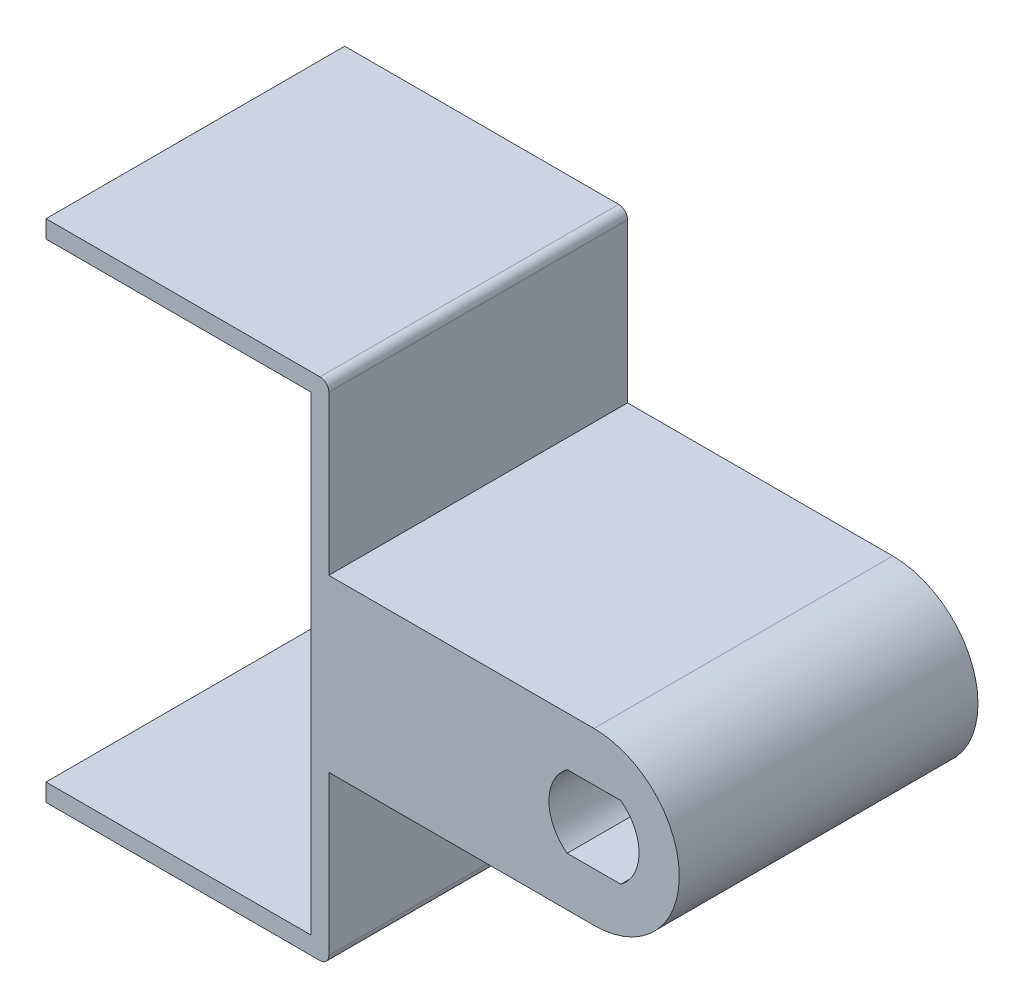
from build123d import *
from OCP.BRepFilletAPI import BRepFilletAPI_MakeChamfer

# Parameters (mm, degrees)
BOSS_EXTRUDE1_DEPTH = 16.9
BOSS_EXTRUDE2_DEPTH = 13.5
BOSS_EXTRUDE3_DEPTH = 3.4
BOSS_EXTRUDE4_DEPTH = 13.5
CUT_EXTRUDE1_DEPTH  = 46.31468443
CHAMFER1_SIZE       = 2
CHAMFER1_SIZE2      = 1.154700538
CUT_EXTRUDE2_DEPTH  = 47.441152279
FILLET1_R           = 0.5
SKETCH10_W          = 25
SKETCH10_H          = 28.6
CUT_EXTRUDE3_DEPTH  = 47.441152315


with BuildPart() as part:
    # Sketch1 → Boss-Extrude1 (new body)
    with BuildSketch(Plane.XY):
        Polygon((-20, -13.3), (20, -13.3), (20, 13.3), (-20, 13.3), (-20, 14.3), (21, 14.3), (21, -14.3), (-20, -14.3), align=None)
    extrude(amount=BOSS_EXTRUDE1_DEPTH)

    # Sketch4 → Boss-Extrude2 (add)
    with BuildSketch(Plane(origin=(0, 0, 0), x_dir=(-1, 0, 0), z_dir=(0, 0, -1))):
        with BuildLine():
            Line((-21, 4.825), (-36, 4.825))
            ThreePointArc((-36, 4.825), (-38.610615349, 4.05774722), (-40.390970849, 2))
            Line((-40.390970849, 2), (-30.875, 2))
            Line((-30.875, 2), (-30.875, -2))
            Line((-30.875, -2), (-40.390970849, -2))
            ThreePointArc((-40.390970849, -2), (-38.610615349, -4.05774722), (-36, -4.825))
            Line((-36, -4.825), (-21, -4.825))
            Line((-21, -4.825), (-21, 4.825))
        make_face()
    extrude(amount=-BOSS_EXTRUDE2_DEPTH)

    # Sketch5 → Boss-Extrude3 (add)
    with BuildSketch(Plane.XY.offset(13.5)):
        with BuildLine():
            Line((21, 4.825), (21, -4.825))
            Line((21, -4.825), (36, -4.825))
            ThreePointArc((36, -4.825), (38.610615349, -4.05774722), (40.390970849, -2))
            ThreePointArc((40.390970849, -2), (40.825, 0), (40.390970849, 2))
            ThreePointArc((40.390970849, 2), (38.610615349, 4.05774722), (36, 4.825))
            Line((36, 4.825), (21, 4.825))
        make_face()
    extrude(amount=BOSS_EXTRUDE3_DEPTH)

    # Sketch8 → Boss-Extrude4 (add)
    with BuildSketch(Plane(origin=(0, 0, 0), x_dir=(-1, 0, 0), z_dir=(0, 0, -1))):
        with BuildLine():
            Line((-37.5, 2), (-40.390970849, 2))
            ThreePointArc((-40.390970849, 2), (-40.825, 0), (-40.390970849, -2))
            Line((-40.390970849, -2), (-37.5, -2))
            ThreePointArc((-37.5, -2), (-38.5, 0), (-37.5, 2))
        make_face()
        with BuildLine():
            Line((-34.5, 2), (-30.875, 2))
            Line((-30.875, 2), (-30.875, -2))
            Line((-30.875, -2), (-34.5, -2))
            ThreePointArc((-34.5, -2), (-33.5, 0), (-34.5, 2))
        make_face()
    extrude(amount=-BOSS_EXTRUDE4_DEPTH)

    # Sketch9 → Cut-Extrude1 (cut, through all)
    with BuildSketch(Plane(origin=(0, 0, 13.5), x_dir=(-1, 0, 0), z_dir=(0, 0, -1))):
        with BuildLine():
            Line((-37.5, -2), (-34.5, -2))
            ThreePointArc((-34.5, -2), (-33.5, 0), (-34.5, 2))
            Line((-34.5, 2), (-37.5, 2))
            ThreePointArc((-37.5, 2), (-38.5, 0), (-37.5, -2))
        make_face()
    extrude(amount=-CUT_EXTRUDE1_DEPTH, mode=Mode.SUBTRACT)

    # Chamfer1: one chamfer whose edges measure the first distance from different faces: ONE call of the kernel's chamfer builder (chamfer() names one face for all edges)
    chamfer1_edges_1 = [part.edges().sort_by_distance(p)[0] for p in [
        (36, 2, 0),
    ]]
    chamfer1_side_1 = [part.faces().sort_by_distance(p)[0] for p in [
        (36, 2, 8.45),
    ]]
    chamfer1_edges_2 = [part.edges().sort_by_distance(p)[0] for p in [
        (38.5, 0, 0),
    ]]
    chamfer1_side_2 = [part.faces().sort_by_distance(p)[0] for p in [
        (38.5, 0, 8.45),
    ]]
    chamfer1_edges_3 = [part.edges().sort_by_distance(p)[0] for p in [
        (36, -2, 0),
    ]]
    chamfer1_side_3 = [part.faces().sort_by_distance(p)[0] for p in [
        (36, -2, 8.45),
    ]]
    chamfer1_edges_4 = [part.edges().sort_by_distance(p)[0] for p in [
        (33.5, 0, 0),
    ]]
    chamfer1_side_4 = [part.faces().sort_by_distance(p)[0] for p in [
        (33.5, 0, 8.45),
    ]]
    chamfer1 = BRepFilletAPI_MakeChamfer(part.part.solid().wrapped)
    for e in chamfer1_edges_1:
        chamfer1.Add(CHAMFER1_SIZE, CHAMFER1_SIZE2, e.wrapped, chamfer1_side_1[0].wrapped)  # the first distance lies on this face
    for e in chamfer1_edges_2:
        chamfer1.Add(CHAMFER1_SIZE, CHAMFER1_SIZE2, e.wrapped, chamfer1_side_2[0].wrapped)  # the first distance lies on this face
    for e in chamfer1_edges_3:
        chamfer1.Add(CHAMFER1_SIZE, CHAMFER1_SIZE2, e.wrapped, chamfer1_side_3[0].wrapped)  # the first distance lies on this face
    for e in chamfer1_edges_4:
        chamfer1.Add(CHAMFER1_SIZE, CHAMFER1_SIZE2, e.wrapped, chamfer1_side_4[0].wrapped)  # the first distance lies on this face
    add(Compound.cast(chamfer1.Shape()), mode=Mode.REPLACE)

    # Sketch11 → Cut-Extrude2 (cut, through all)
    with BuildSketch(Plane(origin=(0, 0, 0), x_dir=(-1, 0, 0), z_dir=(0, 0, -1))):
        with BuildLine():
            Line((-34.483424911, 2.05), (-37.516575089, 2.05))
            ThreePointArc((-37.516575089, 2.05), (-38.55, 0), (-37.516575089, -2.05))
            Line((-37.516575089, -2.05), (-34.483424911, -2.05))
            ThreePointArc((-34.483424911, -2.05), (-33.45, 0), (-34.483424911, 2.05))
        make_face()
    extrude(amount=-CUT_EXTRUDE2_DEPTH, mode=Mode.SUBTRACT)

    # Fillet1
    fillet1_edges = [part.edges().sort_by_distance(p)[0] for p in [
        (-20, 14.3, 8.45),
        (21, 14.3, 8.45),
        (21, -14.3, 8.45),
        (-20, -14.3, 8.45),
    ]]
    fillet(fillet1_edges, radius=FILLET1_R)

    # Sketch10 → Cut-Extrude3 (cut, through all)
    with BuildSketch(Plane(origin=(0, 0, 0), x_dir=(-1, 0, 0), z_dir=(0, 0, -1))):
        with Locations((7.5, 0)):
            Rectangle(SKETCH10_W, SKETCH10_H)
    extrude(amount=-CUT_EXTRUDE3_DEPTH, mode=Mode.SUBTRACT)


solid = part.part
